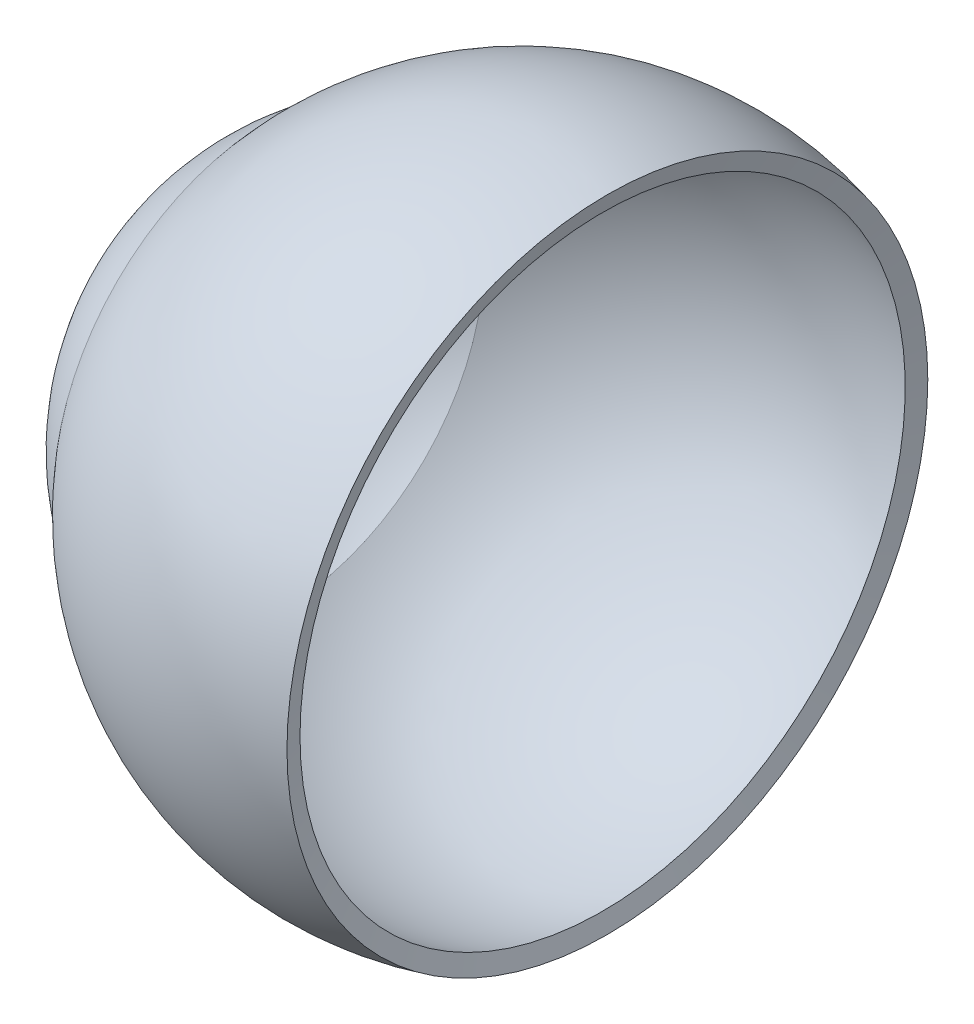
from build123d import *


with BuildPart() as part:
    # Sketch1 → Revolve1 (revolve)
    with BuildSketch(Plane.XY):
        with BuildLine():
            Line((-9.5, 0), (-10, 0))
            ThreePointArc((-10, 0), (-9.157651067, 3.329164059), (-6.833333333, 5.857094464))
            ThreePointArc((-6.833333333, 5.857094464), (-2.661292866, 8.597529894), (2.329371406, 8.693332437))
            Line((2.329371406, 8.693332437), (2.199961883, 8.210369523))
            ThreePointArc((2.199961883, 8.210369523), (-2.547567646, 8.109247751), (-6.5, 5.477225575))
            ThreePointArc((-6.5, 5.477225575), (-8.700877125, 3.122498999), (-9.5, 0))
        make_face()
    revolve(axis=Axis((-10, 0, 0), (1, 0, 0)))


solid = part.part
